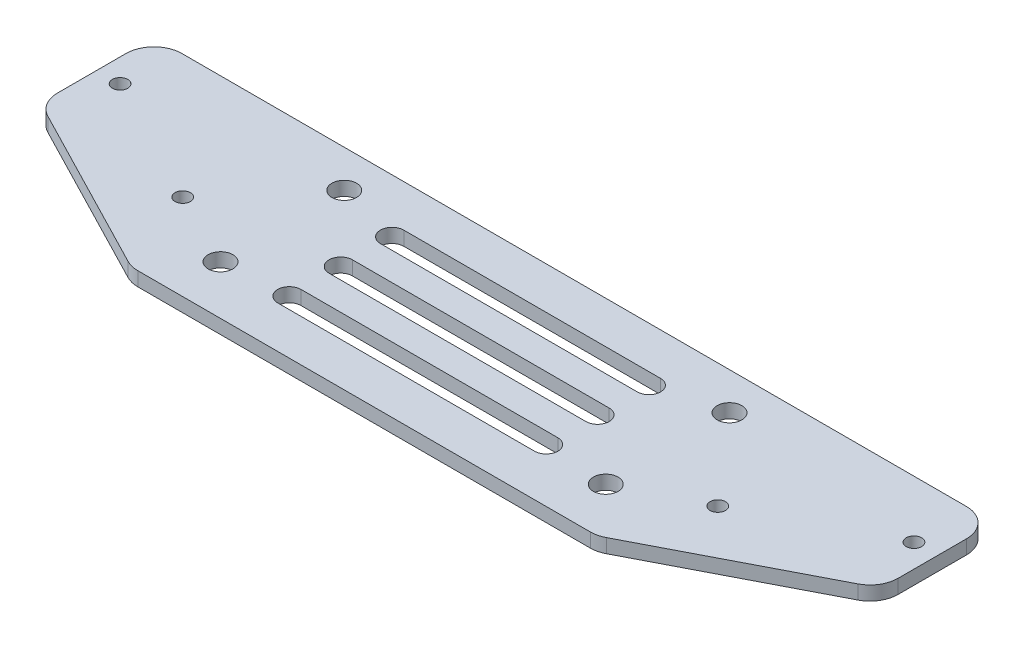
from build123d import *

# Parameters (mm, degrees)
SKETCH_1_W          = 180
SKETCH_1_H          = 45
SKETCH_1_R          = 2.65
EXTRUDE_1_DEPTH     = 3
SKETCH_2_R          = 1.65
CUT_EXTRUDE_1_DEPTH = 3
CUT_EXTRUDE_2_DEPTH = 3
FILLET_1_R          = 6
CUT_EXTRUDE_3_DEPTH = 3


with BuildPart() as part:
    # 草图1 → 凸台-拉伸1 (new body)
    with BuildSketch(Plane(origin=(0, 0, 0), x_dir=(1, 0, 0), z_dir=(0, 1, 0))):
        with Locations((0, -1.25)):
            Rectangle(SKETCH_1_W, SKETCH_1_H)
        with Locations((-41.25, 13.25)):
            Circle(SKETCH_1_R, mode=Mode.SUBTRACT)
        with Locations((41.25, 13.25)):
            Circle(SKETCH_1_R, mode=Mode.SUBTRACT)
        with Locations((-41.25, -13.25)):
            Circle(SKETCH_1_R, mode=Mode.SUBTRACT)
        with Locations((41.25, -13.25)):
            Circle(SKETCH_1_R, mode=Mode.SUBTRACT)
    extrude(amount=EXTRUDE_1_DEPTH)

    # 草图2 → 切除-拉伸1 (cut)
    with BuildSketch(Plane(origin=(0, 3, 0), x_dir=(1, 0, 0), z_dir=(0, 1, 0))):
        with Locations((-85, 9)):
            Circle(SKETCH_2_R)
        with Locations((85, 9)):
            Circle(SKETCH_2_R)
        with Locations((-57.3, -5.3)):
            Circle(SKETCH_2_R)
        with Locations((57.3, -5.3)):
            Circle(SKETCH_2_R)
    extrude(amount=-CUT_EXTRUDE_1_DEPTH, mode=Mode.SUBTRACT)

    # 草图3 → 切除-拉伸2 (cut)
    with BuildSketch(Plane(origin=(0, 3, 0), x_dir=(1, 0, 0), z_dir=(0, 1, 0))):
        Polygon((-90, -3.048881556), (-90, -23.75), (-49.900630707, -23.75), align=None)
        Polygon((90, -23.75), (49.900630707, -23.75), (90, -3.048881556), align=None)
    extrude(amount=-CUT_EXTRUDE_2_DEPTH, mode=Mode.SUBTRACT)

    # 圆角1
    fillet_1_edges = [part.edges().sort_by_distance(p)[0] for p in [
        (-90, 1.5, 3.048881556),
        (-49.900630707, 1.5, 23.75),
        (90, 1.5, 3.048881556),
        (49.900630707, 1.5, 23.75),
        (-90, 1.5, -21.25),
        (90, 1.5, -21.25),
    ]]
    fillet(fillet_1_edges, radius=FILLET_1_R)

    # 草图4 → 切除-拉伸3 (cut)
    with BuildSketch(Plane(origin=(0, 3, 0), x_dir=(1, 0, 0), z_dir=(0, 1, 0))):
        with BuildLine():
            Line((-27.5, 12.25), (27.5, 12.25))
            ThreePointArc((27.5, 12.25), (30, 9.75), (27.5, 7.25))
            Line((27.5, 7.25), (-27.5, 7.25))
            ThreePointArc((-27.5, 7.25), (-30, 9.75), (-27.5, 12.25))
        make_face()
        with BuildLine():
            Line((-27.5, 1.25), (27.5, 1.25))
            ThreePointArc((27.5, 1.25), (30, -1.25), (27.5, -3.75))
            Line((27.5, -3.75), (-27.5, -3.75))
            ThreePointArc((-27.5, -3.75), (-30, -1.25), (-27.5, 1.25))
        make_face()
        with BuildLine():
            Line((-27.5, -9.75), (27.5, -9.75))
            ThreePointArc((27.5, -9.75), (30, -12.25), (27.5, -14.75))
            Line((27.5, -14.75), (-27.5, -14.75))
            ThreePointArc((-27.5, -14.75), (-30, -12.25), (-27.5, -9.75))
        make_face()
    extrude(amount=-CUT_EXTRUDE_3_DEPTH, mode=Mode.SUBTRACT)


solid = part.part
